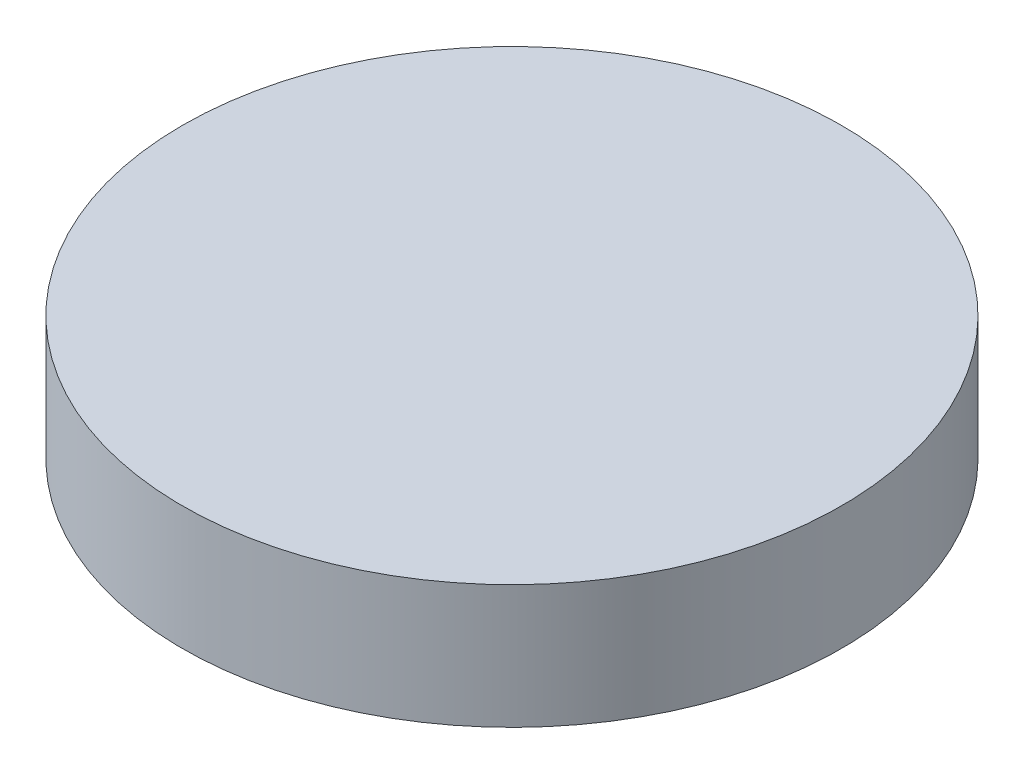
from build123d import *

# Parameters (mm, degrees)
SKETCH1_W = 12.7
SKETCH1_H = 4.7625


with BuildPart() as part:
    # Sketch1 → Revolve1 (revolve)
    with BuildSketch(Plane.XY):
        with Locations((-6.35, 2.38125)):
            Rectangle(SKETCH1_W, SKETCH1_H)
    revolve(axis=Axis((0, 4.7625, 0), (0, -1, 0)))


solid = part.part
